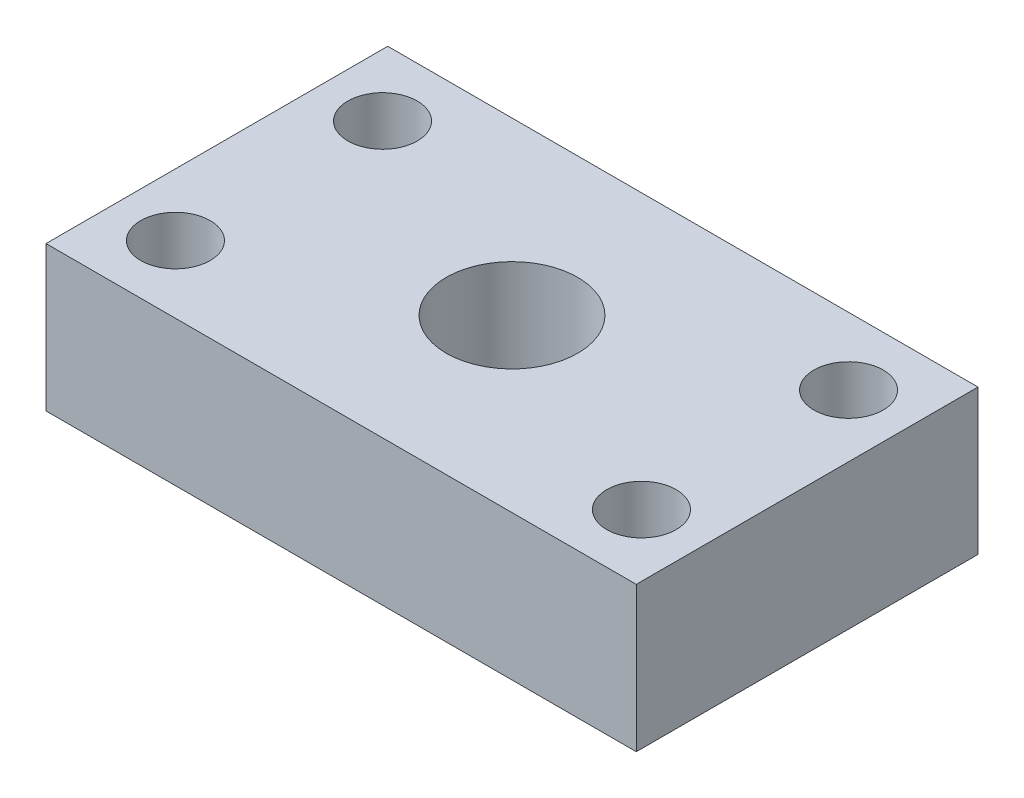
from build123d import *

# Parameters (mm, degrees)
SKETCH1_W                 = 57
SKETCH1_H                 = 33
BOSS_EXTRUDE1_DEPTH       = 14
SKETCH3_R                 = 3.35
CUT_EXTRUDE1_DEPTH        = 15
SKETCH4_R                 = 3.35
CUT_EXTRUDE2_DEPTH        = 15
SKETCH10_R                = 3.35
CUT_EXTRUDE5_DEPTH        = 15
SKETCH12_R                = 3.35
CUT_EXTRUDE6_DEPTH        = 15
F_8_32_TAPPED_HOLE1_D     = 3.4544
F_8_32_TAPPED_HOLE1_DEPTH = 5
F_8_32_TAPPED_HOLE1_TIP   = 1.037806461
F_0_535_40_TAPPED_HOLE1_D = 12.7


with BuildPart() as part:
    # Sketch1 → Boss-Extrude1 (new body)
    with BuildSketch(Plane(origin=(0, 0, 0), x_dir=(1, 0, 0), z_dir=(0, 1, 0))):
        with Locations((28.5, 16.5)):
            Rectangle(SKETCH1_W, SKETCH1_H)
    extrude(amount=BOSS_EXTRUDE1_DEPTH)

    # Sketch3 → Cut-Extrude1 (cut, through all)
    with BuildSketch(Plane.XZ):
        with Locations((6, -6.5)):
            Circle(SKETCH3_R)
    extrude(amount=-CUT_EXTRUDE1_DEPTH, mode=Mode.SUBTRACT)

    # Sketch4 → Cut-Extrude2 (cut, through all)
    with BuildSketch(Plane.XZ):
        with Locations((51, -26.5)):
            Circle(SKETCH4_R)
    extrude(amount=-CUT_EXTRUDE2_DEPTH, mode=Mode.SUBTRACT)

    # Sketch10 → Cut-Extrude5 (cut, through all)
    with BuildSketch(Plane.XZ):
        with Locations((6, -26.5)):
            Circle(SKETCH10_R)
    extrude(amount=-CUT_EXTRUDE5_DEPTH, mode=Mode.SUBTRACT)

    # Sketch12 → Cut-Extrude6 (cut, through all)
    with BuildSketch(Plane.XZ):
        with Locations((51, -6.5)):
            Circle(SKETCH12_R)
    extrude(amount=-CUT_EXTRUDE6_DEPTH, mode=Mode.SUBTRACT)

    # #8-32 Tapped Hole1
    with Locations(Plane(origin=(0, 0, -33), x_dir=(-1, 0, 0), z_dir=(0, 0, -1))):
        with Locations((-28.5, 7)):
            Hole(F_8_32_TAPPED_HOLE1_D / 2, depth=F_8_32_TAPPED_HOLE1_DEPTH)
            with Locations((0, 0, -(F_8_32_TAPPED_HOLE1_DEPTH + F_8_32_TAPPED_HOLE1_TIP / 2))):  # 118° drill point
                Cone(0, F_8_32_TAPPED_HOLE1_D / 2, F_8_32_TAPPED_HOLE1_TIP, mode=Mode.SUBTRACT)

    # 0.535-40 Tapped Hole1 (through all)
    with Locations(Plane(origin=(0, 14, 0), x_dir=(1, 0, 0), z_dir=(0, 1, 0))):
        with Locations((28.5, 16.5)):
            Hole(F_0_535_40_TAPPED_HOLE1_D / 2)


solid = part.part
